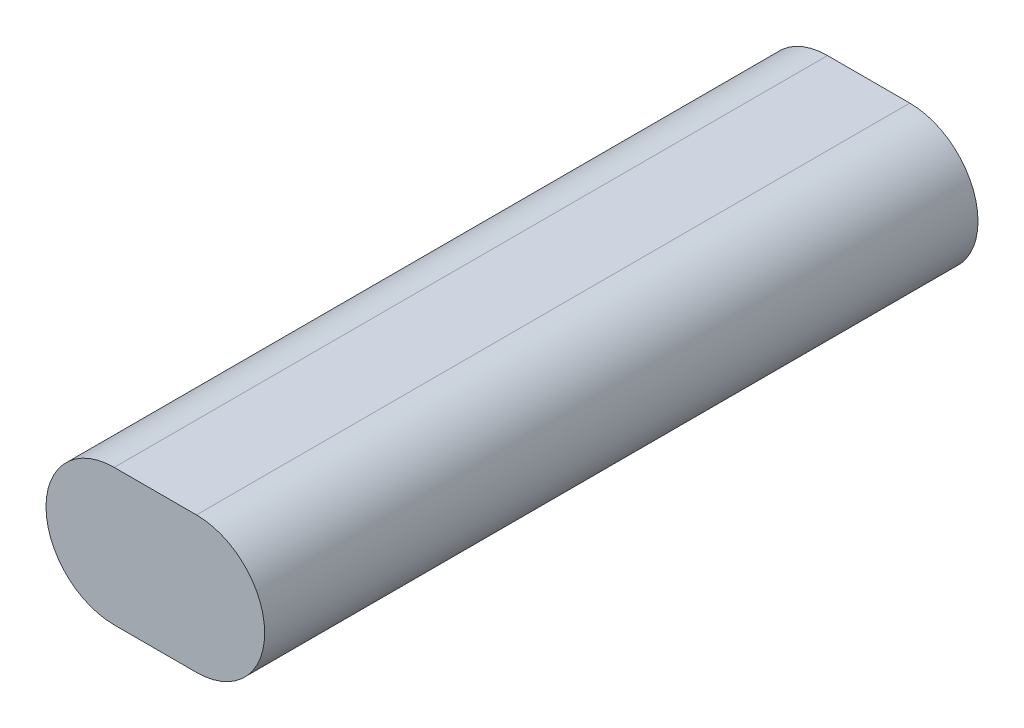
from build123d import *

# Parameters (mm, degrees)
BOSS_EXTRUDE1_DEPTH = 168.91
BOSS_EXTRUDE2_DEPTH = 5.08
SKETCH5_R           = 3.683
CUT_EXTRUDE2_DEPTH  = 4.191
SKETCH6_R           = 2.286
CUT_EXTRUDE3_DEPTH  = 6.731


with BuildPart() as part:
    # Sketch1 → Boss-Extrude1 (new body)
    with BuildSketch(Plane.XY):
        with BuildLine():
            ThreePointArc((-24.13, 0), (-20.74503307, 8.17203307), (-12.573, 11.557))
            Line((-12.573, 11.557), (12.573, 11.557))
            ThreePointArc((12.573, 11.557), (20.74503307, 8.17203307), (24.13, 0))
            Line((24.13, 0), (26.67, 0))
            ThreePointArc((26.67, 0), (21.797135519, 11.764135519), (10.033, 16.637))
            Line((10.033, 16.637), (-10.033, 16.637))
            ThreePointArc((-10.033, 16.637), (-21.797135519, 11.764135519), (-26.67, 0))
            Line((-26.67, 0), (-24.13, 0))
        make_face()
        with BuildLine():
            ThreePointArc((-12.573, -11.557), (-20.74503307, -8.17203307), (-24.13, 0))
            Line((-24.13, 0), (-26.67, 0))
            ThreePointArc((-26.67, 0), (-21.797135519, -11.764135519), (-10.033, -16.637))
            Line((-10.033, -16.637), (10.033, -16.637))
            ThreePointArc((10.033, -16.637), (21.797135519, -11.764135519), (26.67, 0))
            Line((26.67, 0), (24.13, 0))
            ThreePointArc((24.13, 0), (20.74503307, -8.17203307), (12.573, -11.557))
            Line((12.573, -11.557), (-12.573, -11.557))
        make_face()
    extrude(amount=-BOSS_EXTRUDE1_DEPTH)

    # Sketch3 → Boss-Extrude2 (add)
    with BuildSketch(Plane.XY):
        with BuildLine():
            Line((-10.033, 16.637), (10.033, 16.637))
            ThreePointArc((10.033, 16.637), (26.67, 0), (10.033, -16.637))
            Line((10.033, -16.637), (-10.033, -16.637))
            ThreePointArc((-10.033, -16.637), (-26.67, 0), (-10.033, 16.637))
        make_face()
    extrude(amount=BOSS_EXTRUDE2_DEPTH)

    # Sketch5 → Cut-Extrude2 (cut)
    with BuildSketch(Plane(origin=(0, -11.557, 0), x_dir=(1, 0, 0), z_dir=(0, 1, 0))):
        with Locations((0, 110.998)):
            Circle(SKETCH5_R)
        with Locations((0, 52.832)):
            Circle(SKETCH5_R)
    extrude(amount=-CUT_EXTRUDE2_DEPTH, mode=Mode.SUBTRACT)

    # Sketch6 → Cut-Extrude3 (cut)
    with BuildSketch(Plane(origin=(0, -11.557, 0), x_dir=(1, 0, 0), z_dir=(0, 1, 0))):
        with Locations((0, 110.998)):
            Circle(SKETCH6_R)
        with Locations((0, 52.832)):
            Circle(SKETCH6_R)
    extrude(amount=-CUT_EXTRUDE3_DEPTH, mode=Mode.SUBTRACT)


solid = part.part
